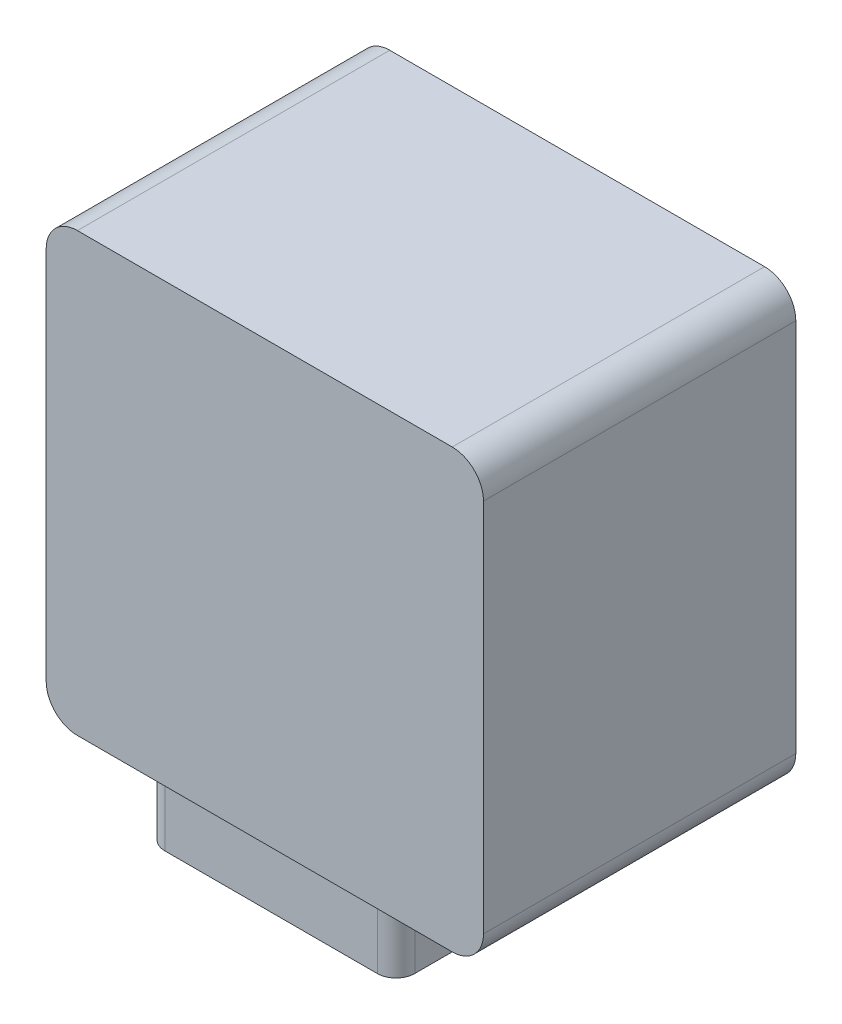
from build123d import *

# Parameters (mm, degrees)
EXTRUDE_1_DEPTH = 50
SKETCH_2_R      = 3
EXTRUDE_2_DEPTH = 10


with BuildPart() as part:
    # 草图1 → 凸台-拉伸1 (new body)
    with BuildSketch(Plane.XY):
        with BuildLine():
            Line((-48.193457488, 66.287565891), (11.806542512, 66.287565891))
            ThreePointArc((11.806542512, 66.287565891), (15.342076418, 64.823099797), (16.806542512, 61.287565891))
            Line((16.806542512, 61.287565891), (16.806542512, 1.287565891))
            ThreePointArc((16.806542512, 1.287565891), (15.342076418, -2.247968015), (11.806542512, -3.712434109))
            Line((11.806542512, -3.712434109), (-48.193457488, -3.712434109))
            ThreePointArc((-48.193457488, -3.712434109), (-51.728991394, -2.247968015), (-53.193457488, 1.287565891))
            Line((-53.193457488, 1.287565891), (-53.193457488, 61.287565891))
            ThreePointArc((-53.193457488, 61.287565891), (-51.728991394, 64.823099797), (-48.193457488, 66.287565891))
        make_face()
    extrude(amount=EXTRUDE_1_DEPTH)

    # 草图2 → 凸台-拉伸2 (add)
    with BuildSketch(Plane.XZ.offset(3.712434109)):
        with BuildLine():
            Line((-18.193457488, 9), (-35.193457488, 9))
            ThreePointArc((-35.193457488, 9), (-37.314777832, 9.878679656), (-38.193457488, 12))
            Line((-38.193457488, 12), (-38.193457488, 46))
            ThreePointArc((-38.193457488, 46), (-37.314777832, 48.121320344), (-35.193457488, 49))
            Line((-35.193457488, 49), (-1.193457488, 49))
            ThreePointArc((-1.193457488, 49), (0.927862855, 48.121320344), (1.806542512, 46))
            Line((1.806542512, 46), (1.806542512, 12))
            ThreePointArc((1.806542512, 12), (0.927862855, 9.878679656), (-1.193457488, 9))
            Line((-1.193457488, 9), (-18.193457488, 9))
        make_face()
        with Locations((-18.193457488, 41.5)):
            Circle(SKETCH_2_R, mode=Mode.SUBTRACT)
        with Locations((-30.693457488, 29)):
            Circle(SKETCH_2_R, mode=Mode.SUBTRACT)
        with Locations((-18.193457488, 16.5)):
            Circle(SKETCH_2_R, mode=Mode.SUBTRACT)
        with Locations((-5.693457488, 29)):
            Circle(SKETCH_2_R, mode=Mode.SUBTRACT)
    extrude(amount=EXTRUDE_2_DEPTH)


solid = part.part
